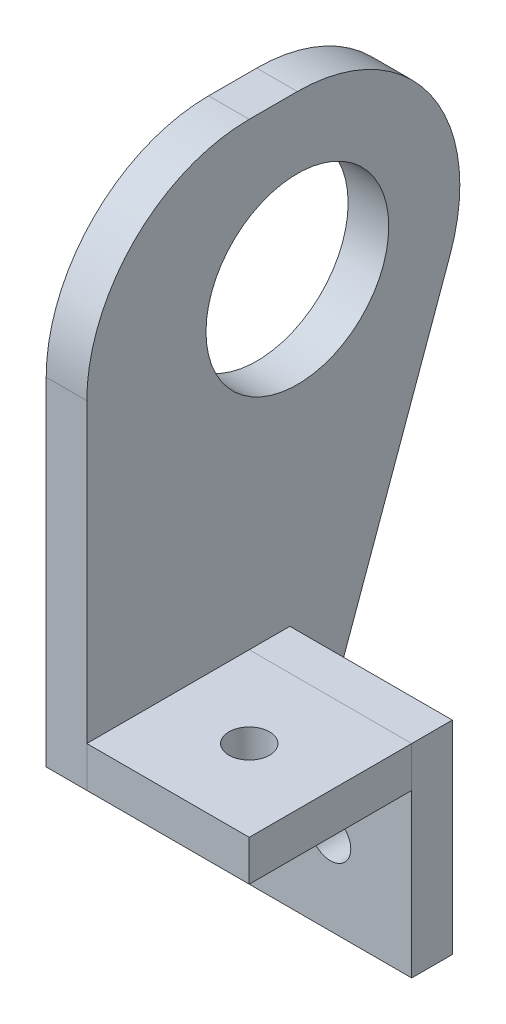
from build123d import *

# Parameters (mm, degrees)
SKETCH1_R           = 14.2875
BOSS_EXTRUDE1_DEPTH = 6.35
SKETCH2_W           = 25.4
SKETCH2_H           = 6.35
BOSS_EXTRUDE2_DEPTH = 25.4
FILLET1_R           = 25.4
SKETCH3_W           = 6.35
SKETCH3_H           = 31.75
BOSS_EXTRUDE3_DEPTH = 25.4
SKETCH4_R           = 3.175
CUT_EXTRUDE1_DEPTH  = 79.175
SKETCH5_R           = 3.175
CUT_EXTRUDE2_DEPTH  = 33.925


with BuildPart() as part:
    # Sketch1 → Boss-Extrude1 (new body)
    with BuildSketch(Plane(origin=(0, 0, 0), x_dir=(0, 0, -1), z_dir=(1, 0, 0))):
        with BuildLine():
            Line((0, 25.4), (-32.925, 25.4))
            Line((-32.925, 25.4), (-32.925, -52.775))
            Line((-32.925, -52.775), (-9.1125, -52.775))
            ThreePointArc((-9.1125, -52.775), (-7.989967985, -53.239967985), (-7.525, -54.3625))
            Line((-7.525, -54.3625), (-7.525, -78.175))
            Line((-7.525, -78.175), (-1.175, -78.175))
            Line((-1.175, -78.175), (23.895496523, -8.611924636))
            ThreePointArc((23.895496523, -8.611924636), (20.783441555, 14.601662821), (0, 25.4))
        make_face()
        Circle(SKETCH1_R, mode=Mode.SUBTRACT)
    extrude(amount=BOSS_EXTRUDE1_DEPTH)

    # Fillet1
    fillet1_edges = [part.edges().sort_by_distance(p)[0] for p in [
        (3.175, 25.4, 32.925),
    ]]
    fillet(fillet1_edges, radius=FILLET1_R)


with BuildPart() as body_2:
    # Sketch2 → Boss-Extrude2 (new body)
    with BuildSketch(Plane(origin=(6.35, 0, 0), x_dir=(0, 0, -1), z_dir=(1, 0, 0))):
        with Locations((-20.225, -49.6)):
            Rectangle(SKETCH2_W, SKETCH2_H)
    extrude(amount=BOSS_EXTRUDE2_DEPTH)

    # Sketch4 → Cut-Extrude1 (cut, through all)
    with BuildSketch(Plane.XZ.offset(52.775)):
        with Locations((19.05, 20.225)):
            Circle(SKETCH4_R)
    extrude(amount=-CUT_EXTRUDE1_DEPTH, mode=Mode.SUBTRACT)


with BuildPart() as body_3:
    # Sketch3 → Boss-Extrude3 (new body)
    with BuildSketch(Plane(origin=(6.35, 0, 0), x_dir=(0, 0, -1), z_dir=(1, 0, 0))):
        with Locations((-4.35, -62.3)):
            Rectangle(SKETCH3_W, SKETCH3_H)
    extrude(amount=BOSS_EXTRUDE3_DEPTH)

    # Sketch5 → Cut-Extrude2 (cut, through all)
    with BuildSketch(Plane.XY.offset(7.525)):
        with Locations((19.05, -65.475)):
            Circle(SKETCH5_R)
    extrude(amount=-CUT_EXTRUDE2_DEPTH, mode=Mode.SUBTRACT)


solid = Compound([part.part, body_2.part, body_3.part])
